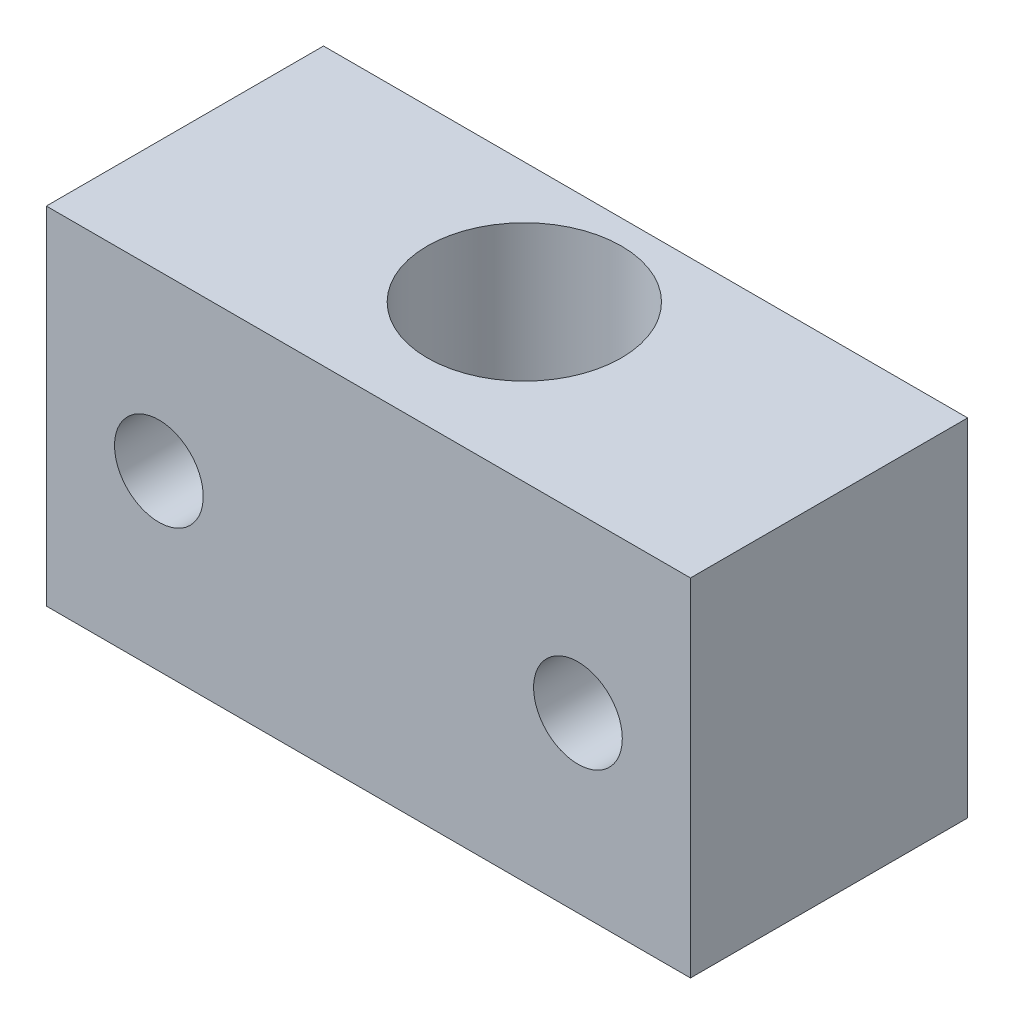
from build123d import *

# Parameters (mm, degrees)
SKETCH1_W           = 29.513896991
SKETCH1_H           = 12.7
SKETCH1_R           = 4.445
BOSS_EXTRUDE1_DEPTH = 15.875
SKETCH2_R           = 2.032
CUT_EXTRUDE1_DEPTH  = 12.7


with BuildPart() as part:
    # Sketch1 → Boss-Extrude1 (new body)
    with BuildSketch(Plane(origin=(0, 0, 0), x_dir=(1, 0, 0), z_dir=(0, 1, 0))):
        with Locations((14.756948496, 6.35)):
            Rectangle(SKETCH1_W, SKETCH1_H)
        with Locations((14.756948496, 7.14375)):
            Circle(SKETCH1_R, mode=Mode.SUBTRACT)
    extrude(amount=BOSS_EXTRUDE1_DEPTH)

    # Sketch2 → Cut-Extrude1 (cut)
    with BuildSketch(Plane(origin=(0, 0, -12.7), x_dir=(-1, 0, 0), z_dir=(0, 0, -1))):
        with Locations((-5.155974248, 7.9375)):
            Circle(SKETCH2_R)
        with Locations((-24.357922743, 7.9375)):
            Circle(SKETCH2_R)
    extrude(amount=-CUT_EXTRUDE1_DEPTH, mode=Mode.SUBTRACT)


solid = part.part
